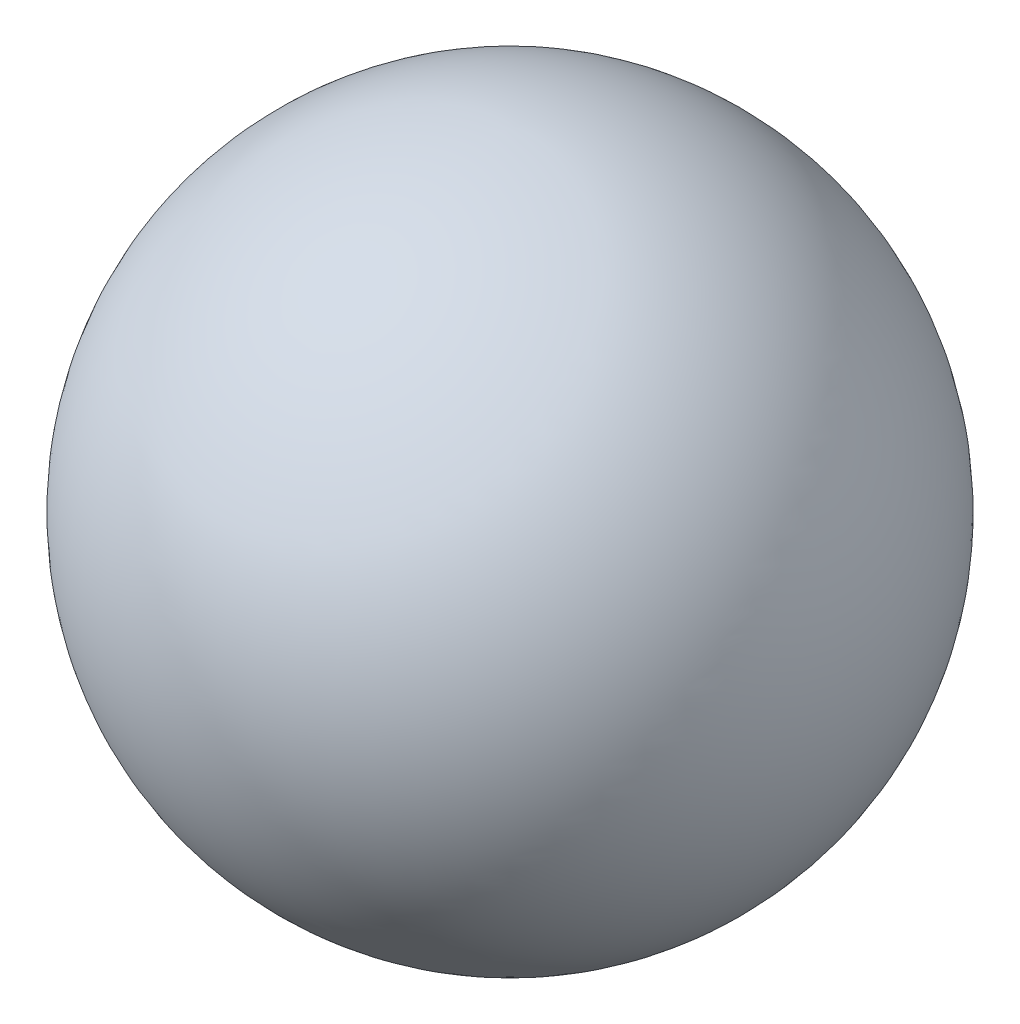
from build123d import *


with BuildPart() as part:
    # Sketch1 → Revolve1 (revolve)
    with BuildSketch(Plane.XY):
        with BuildLine():
            Line((0, 6.35), (0, -6.35))
            ThreePointArc((0, -6.35), (6.26141623, 0), (0, 6.35))
        make_face()
    revolve(axis=Axis((0, 6.35, 0), (0, -1, 0)))


solid = part.part
